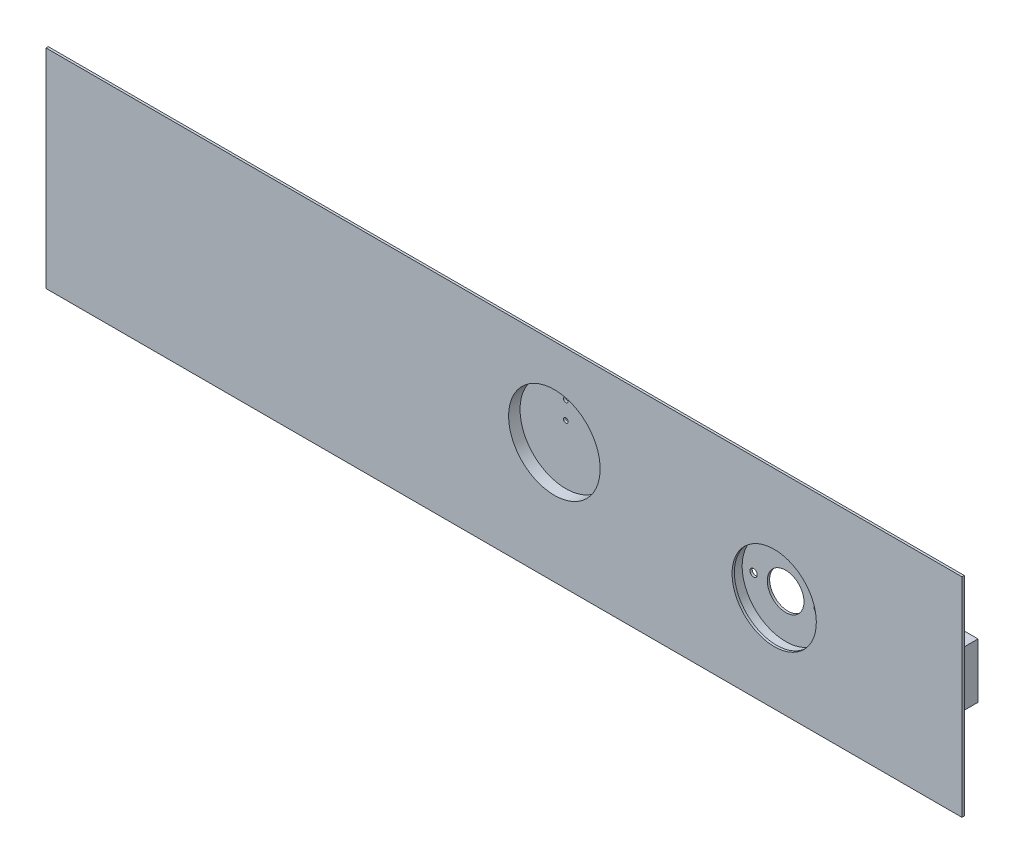
from build123d import *

# Parameters (mm, degrees)
SKETCH1_R               = 31.75
SKETCH1_R_2             = 12.7
SKETCH1_R_3             = 2.54
BOSS_EXTRUDE1_DEPTH     = 1.5875
SKETCH3_W               = 635
SKETCH3_H               = 144.4625
SKETCH3_R               = 29.21
BOSS_EXTRUDE2_DEPTH     = 1.5875
SKETCH4_R               = 41.275
SKETCH5_R               = 31.75
SKETCH6_R               = 30.1625
TIMER_HOLE_DEPTH        = 6.35
SKETCH7_W               = 19.05
SKETCH7_H               = 38.1
SOAK_LIGHT_DEPTH        = 25.4
SKETCH8_R               = 44.45
SKETCH9_R               = 31.75
SKETCH10_R              = 31.75
CUT_EXTRUDE1_DEPTH      = 6.35
CUT_EXTRUDE1_DEPTH_BACK = 2.5875
SKETCH11_R              = 1.651
CUT_EXTRUDE2_DEPTH      = 10.525


with BuildPart() as part:
    # Sketch1 → Boss-Extrude1 (new body)
    with BuildSketch(Plane.XY):
        Circle(SKETCH1_R)
        Circle(SKETCH1_R_2, mode=Mode.SUBTRACT)
        with Locations((-22.225, 0)):
            Circle(SKETCH1_R_3, mode=Mode.SUBTRACT)
        with Locations((22.225, 0)):
            Circle(SKETCH1_R_3, mode=Mode.SUBTRACT)
    extrude(amount=BOSS_EXTRUDE1_DEPTH)



with BuildPart() as body_2:
    # Sketch3 → Boss-Extrude2 (new body)
    with BuildSketch(Plane.XY.offset(7.9375)):
        with Locations((-187.325, 5.55625)):
            Rectangle(SKETCH3_W, SKETCH3_H)
        Circle(SKETCH3_R, mode=Mode.SUBTRACT)
    extrude(amount=BOSS_EXTRUDE2_DEPTH)


with BuildPart() as part_1:
    add(part.part)

    add(body_2.part)  # Loft1 merges body 2
    # Sketch4 → Loft1 section 0
    with BuildSketch(Plane(origin=(0, 0, 7.9375), x_dir=(-1, 0, 0), z_dir=(0, 0, -1))):
        Circle(SKETCH4_R)
    # Sketch5 → Loft1 section 1
    with BuildSketch(Plane(origin=(0, 0, 1.5875), x_dir=(-1, 0, 0), z_dir=(0, 0, -1))):
        Circle(SKETCH5_R)
    loft()

    # Sketch6 → Timer hole (cut)
    with BuildSketch(Plane(origin=(0, 0, 7.9375), x_dir=(-1, 0, 0), z_dir=(0, 0, -1))):
        Circle(SKETCH6_R)
    extrude(amount=TIMER_HOLE_DEPTH, mode=Mode.SUBTRACT)

    # Sketch7 → Soak light (add)
    with BuildSketch(Plane(origin=(0, 0, 7.9375), x_dir=(-1, 0, 0), z_dir=(0, 0, -1))):
        with Locations((-104.775, 0)):
            Rectangle(SKETCH7_W, SKETCH7_H)
    extrude(amount=SOAK_LIGHT_DEPTH)

    # Sketch8 → spare mount section 0
    with BuildSketch(Plane(origin=(0, 0, 7.9375), x_dir=(-1, 0, 0), z_dir=(0, 0, -1))):
        with Locations((152.4, 17.145)):
            Circle(SKETCH8_R)
    # Sketch9 → spare mount section 1
    with BuildSketch(Plane(origin=(0, 0, 0), x_dir=(-1, 0, 0), z_dir=(0, 0, -1))):
        with Locations((152.4, 17.145)):
            Circle(SKETCH9_R)
    loft()

    # Sketch10 → Cut-Extrude1 (cut, two sides)
    with BuildSketch(Plane(origin=(0, 0, 7.9375), x_dir=(-1, 0, 0), z_dir=(0, 0, -1))) as cut_extrude1_sk:
        with Locations((152.4, 17.145)):
            Circle(SKETCH10_R)
    extrude(amount=CUT_EXTRUDE1_DEPTH, mode=Mode.SUBTRACT)
    extrude(cut_extrude1_sk.sketch, amount=-CUT_EXTRUDE1_DEPTH_BACK, mode=Mode.SUBTRACT)

    # Sketch11 → Cut-Extrude2 (cut, through all)
    with BuildSketch(Plane(origin=(0, 0, 0), x_dir=(-1, 0, 0), z_dir=(0, 0, -1))):
        with Locations((152.4, 26.416)):
            Circle(SKETCH11_R)
        with Locations((152.4, 38.735)):
            Circle(SKETCH11_R)
    extrude(amount=-CUT_EXTRUDE2_DEPTH, mode=Mode.SUBTRACT)


solid = part_1.part
